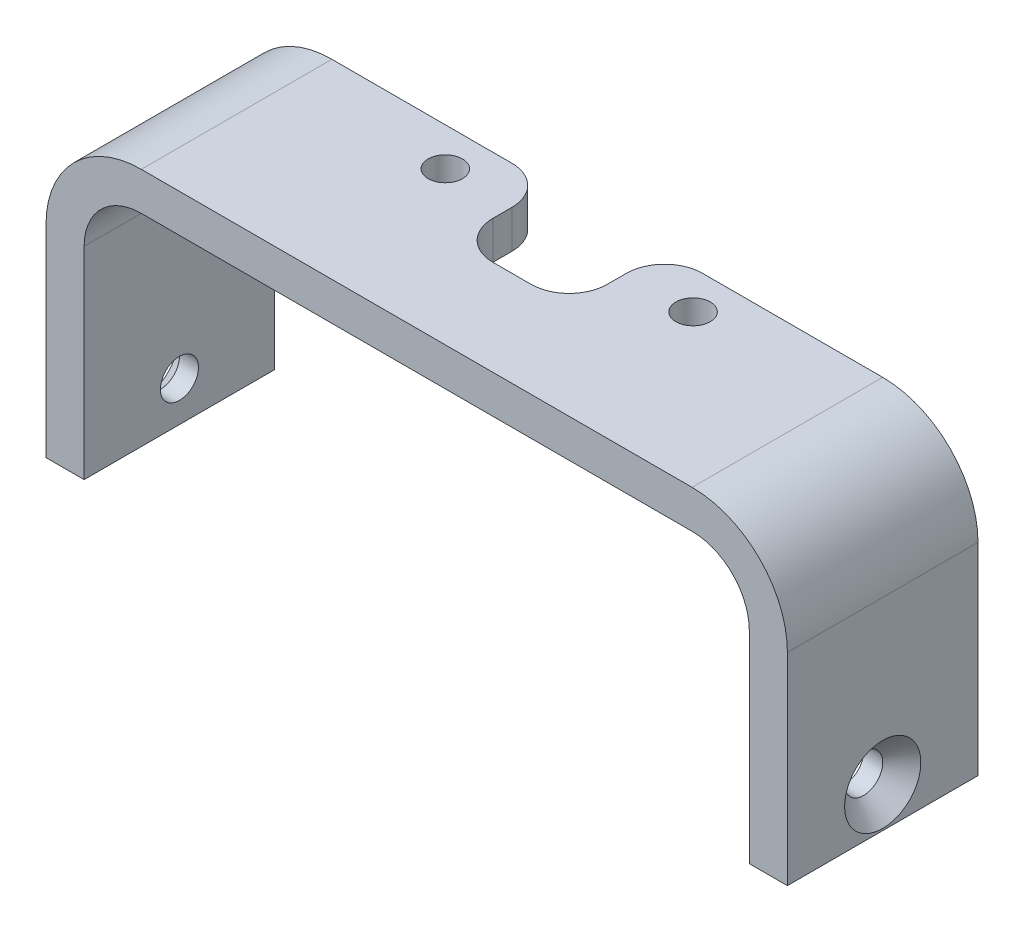
from build123d import *

# Parameters (mm, degrees)
BOSS_EXTRUDE1_DEPTH     = 10
SKETCH2_R               = 1
CUT_EXTRUDE1_DEPTH      = 1
CUT_EXTRUDE1_DEPTH_BACK = 39.9
CHAMFER1_SIZE           = 1
SKETCH3_R               = 0.9
SKETCH3_W               = 6
SKETCH3_H               = 5
CUT_EXTRUDE2_DEPTH      = 16.6
FILLET1_R               = 2


with BuildPart() as part:
    # Sketch1 → Boss-Extrude1 (new body)
    with BuildSketch(Plane.XY):
        with BuildLine():
            Line((17.45, 0), (19.45, 0))
            Line((19.45, 0), (19.45, 10.6))
            ThreePointArc((19.45, 10.6), (17.985533906, 14.135533906), (14.45, 15.6))
            Line((14.45, 15.6), (-14.45, 15.6))
            ThreePointArc((-14.45, 15.6), (-17.985533906, 14.135533906), (-19.45, 10.6))
            Line((-19.45, 10.6), (-19.45, 0))
            Line((-19.45, 0), (-17.45, 0))
            Line((-17.45, 0), (-17.45, 10.6))
            ThreePointArc((-17.45, 10.6), (-16.571320344, 12.721320344), (-14.45, 13.6))
            Line((-14.45, 13.6), (14.45, 13.6))
            ThreePointArc((14.45, 13.6), (16.571320344, 12.721320344), (17.45, 10.6))
            Line((17.45, 10.6), (17.45, 0))
        make_face()
    extrude(amount=BOSS_EXTRUDE1_DEPTH)

    # Sketch2 → Cut-Extrude1 (cut, two sides)
    with BuildSketch(Plane(origin=(19.45, 0, 0), x_dir=(0, 0, -1), z_dir=(1, 0, 0))) as cut_extrude1_sk:
        with Locations((-5, 2.1)):
            Circle(SKETCH2_R)
    extrude(amount=CUT_EXTRUDE1_DEPTH, mode=Mode.SUBTRACT)
    extrude(cut_extrude1_sk.sketch, amount=-CUT_EXTRUDE1_DEPTH_BACK, mode=Mode.SUBTRACT)

    # Chamfer1
    chamfer1_edges = [part.edges().sort_by_distance(p)[0] for p in [
        (-19.45, 2.1, 6),
        (19.45, 2.1, 6),
    ]]
    chamfer(chamfer1_edges, length=CHAMFER1_SIZE)

    # Sketch3 → Cut-Extrude2 (cut, through all)
    with BuildSketch(Plane(origin=(0, 15.6, 0), x_dir=(1, 0, 0), z_dir=(0, 1, 0))):
        with Locations((-6.5, -2)):
            Circle(SKETCH3_R)
        with Locations((6.5, -2)):
            Circle(SKETCH3_R)
        with Locations((0, -2.5)):
            Rectangle(SKETCH3_W, SKETCH3_H)
    extrude(amount=-CUT_EXTRUDE2_DEPTH, mode=Mode.SUBTRACT)

    # Fillet1
    fillet1_edges = [part.edges().sort_by_distance(p)[0] for p in [
        (-3, 14.6, 0),
        (3, 14.6, 0),
        (3, 14.6, 5),
        (-3, 14.6, 5),
    ]]
    fillet(fillet1_edges, radius=FILLET1_R)


solid = part.part
